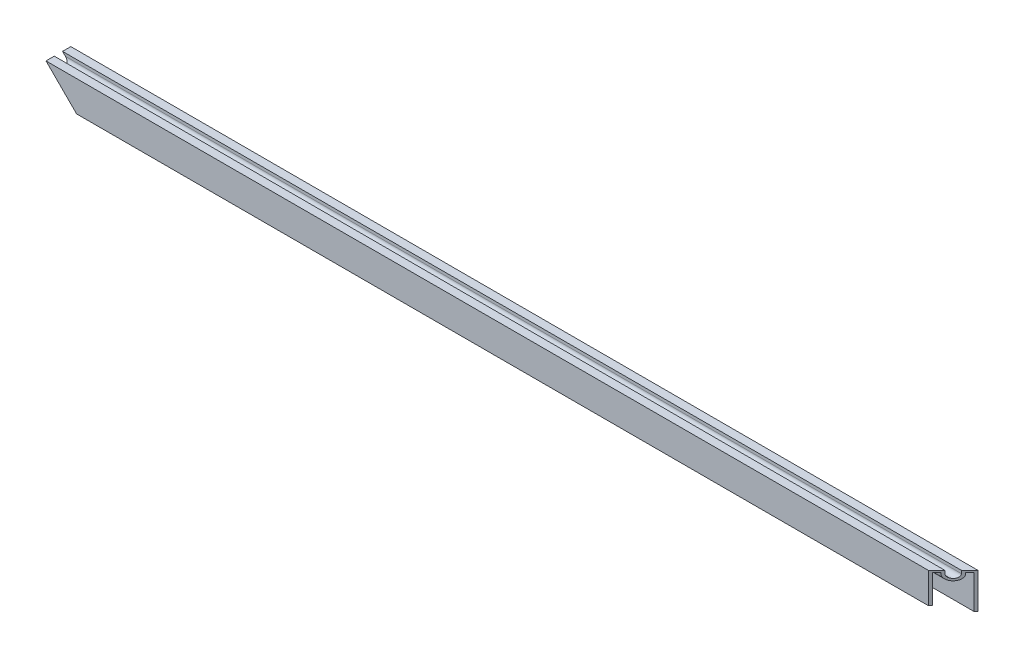
from build123d import *

# Parameters (mm, degrees)
BOSS_EXTRUDE1_DEPTH         = 278.60625
CUT_FRONT_LEFT_BOTTOM_DEPTH = 16.24
CUT_TOP_RIGHT_FRONT_DEPTH   = 22.844


with BuildPart() as part:
    # Sketch1 → Boss-Extrude1 (new body, symmetric)
    with BuildSketch(Plane(origin=(0, 0, 0), x_dir=(0, 0, -1), z_dir=(1, 0, 0))):
        with BuildLine():
            Line((0, 0), (0, 21.844))
            Line((0, 21.844), (-5.08, 21.844))
            Line((-5.08, 21.844), (-5.08, 20.066))
            ThreePointArc((-5.08, 20.066), (-7.62, 17.526), (-10.16, 20.066))
            Line((-10.16, 20.066), (-10.16, 21.844))
            Line((-10.16, 21.844), (-15.24, 21.844))
            Line((-15.24, 21.844), (-15.24, 3.048))
            Line((-15.24, 3.048), (-13.97, 3.048))
            Line((-13.97, 3.048), (-13.97, 20.574))
            Line((-13.97, 20.574), (-11.43, 20.574))
            Line((-11.43, 20.574), (-11.43, 20.066))
            ThreePointArc((-11.43, 20.066), (-7.62, 16.256), (-3.81, 20.066))
            Line((-3.81, 20.066), (-3.81, 20.574))
            Line((-3.81, 20.574), (-1.27, 20.574))
            Line((-1.27, 20.574), (-1.27, 0))
            Line((-1.27, 0), (0, 0))
        make_face()
    extrude(amount=BOSS_EXTRUDE1_DEPTH, both=True)

    # Sketch7 → Cut-Front-Left-Bottom (cut, through all)
    with BuildSketch(Plane.XY.offset(15.24)):
        Polygon((-278.60625, 21.844), (-256.76225, 0), (-278.60625, 0), align=None)
    extrude(amount=-CUT_FRONT_LEFT_BOTTOM_DEPTH, mode=Mode.SUBTRACT)

    # Sketch2 → Cut-Top-Right-Front (cut, through all)
    with BuildSketch(Plane(origin=(0, 21.844, 0), x_dir=(1, 0, 0), z_dir=(0, 1, 0))):
        Polygon((278.60625, 0), (263.36625, -15.24), (278.60625, -15.24), align=None)
    extrude(amount=-CUT_TOP_RIGHT_FRONT_DEPTH, mode=Mode.SUBTRACT)


solid = part.part
